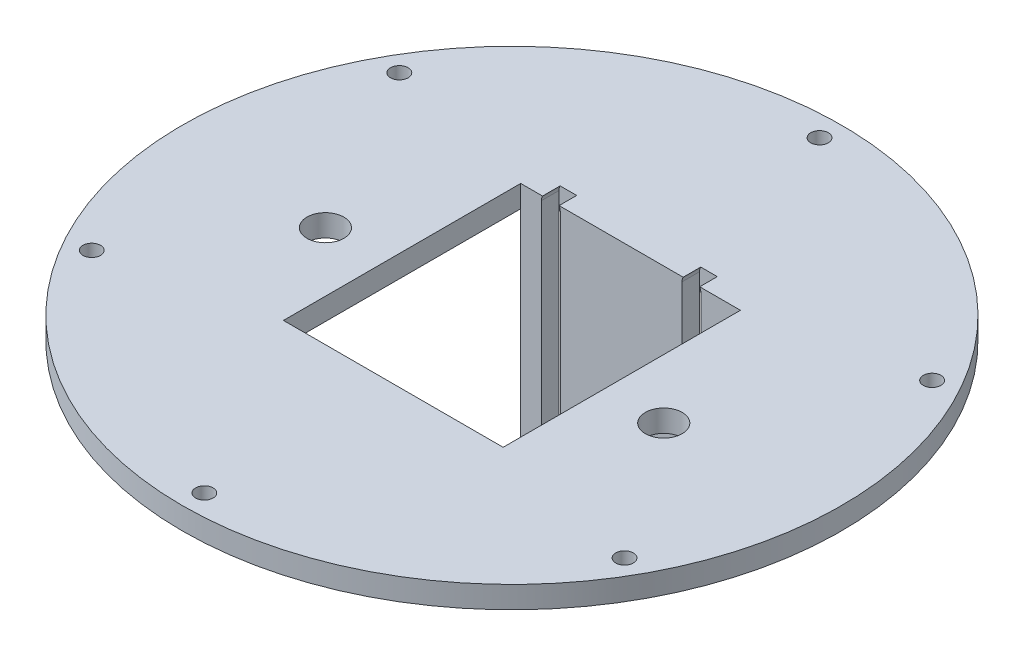
from build123d import *

# Parameters (mm, degrees)
SKETCH1_W           = 200
SKETCH1_H           = 100
BOSS_EXTRUDE1_DEPTH = 5
SKETCH2_W           = 50
SKETCH2_H           = 54
CUT_EXTRUDE1_DEPTH  = 6
SKETCH3_W           = 50
SKETCH3_H           = 4
BOSS_EXTRUDE2_DEPTH = 45
CUT_EXTRUDE3_DEPTH  = 4
SKETCH19_W          = 200
SKETCH19_H          = 5
BOSS_EXTRUDE3_DEPTH = 25
SKETCH20_W          = 200
SKETCH20_H          = 5
BOSS_EXTRUDE4_DEPTH = 25
SKETCH21_W          = 150
SKETCH21_H          = 5
BOSS_EXTRUDE5_DEPTH = 25
SKETCH22_OUTSIDE_W  = 282
SKETCH22_OUTSIDE_H  = 207
SKETCH22_OUTSIDE_R  = 75
CUT_EXTRUDE6_DEPTH  = 51
SKETCH26_R          = 2
CUT_EXTRUDE7_DEPTH  = 51
CUT_EXTRUDE8_REACH  = 52
SKETCH28_R          = 4.2
CUT_EXTRUDE10_DEPTH = 4


with BuildPart() as part:
    # Sketch1 → Boss-Extrude1 (new body)
    with BuildSketch(Plane(origin=(0, 0, 0), x_dir=(1, 0, 0), z_dir=(0, 1, 0))):
        Rectangle(SKETCH1_W, SKETCH1_H)
    extrude(amount=BOSS_EXTRUDE1_DEPTH)

    # Sketch2 → Cut-Extrude1 (cut, through all)
    with BuildSketch(Plane(origin=(0, 5, 0), x_dir=(1, 0, 0), z_dir=(0, 1, 0))):
        with Locations((30, 0)):
            Rectangle(SKETCH2_W, SKETCH2_H)
    extrude(amount=-CUT_EXTRUDE1_DEPTH, mode=Mode.SUBTRACT)

    # Sketch3 → Boss-Extrude2 (add)
    with BuildSketch(Plane.XZ):
        with Locations((30, -29)):
            Rectangle(SKETCH3_W, SKETCH3_H)
    extrude(amount=BOSS_EXTRUDE2_DEPTH)

    # Sketch4 → Cut-Extrude3 (cut)
    with BuildSketch(Plane.XY.offset(-27)):
        with BuildLine():
            ThreePointArc((14, 3.960327286), (11.85, 6.110327286), (9.7, 3.960327286))
            Line((9.7, 3.960327286), (9.7, -6.197738793))
            Line((9.7, -6.197738793), (14, -6.197264156))
            Line((14, -6.197264156), (14, 3.960327286))
        make_face()
        with BuildLine():
            Line((41.7, 3.960327286), (41.7, -31.94922721))
            ThreePointArc((41.7, -31.94922721), (43.85, -34.09922721), (46, -31.94922721))
            Line((46, -31.94922721), (46, 3.960327286))
            ThreePointArc((46, 3.960327286), (43.85, 6.110327286), (41.7, 3.960327286))
        make_face()
    extrude(amount=-CUT_EXTRUDE3_DEPTH, mode=Mode.SUBTRACT)

    # Sketch19 → Boss-Extrude3 (add)
    with BuildSketch(Plane(origin=(0, 0, -50), x_dir=(-1, 0, 0), z_dir=(0, 0, -1))):
        with Locations((0, 2.5)):
            Rectangle(SKETCH19_W, SKETCH19_H)
    extrude(amount=BOSS_EXTRUDE3_DEPTH)

    # Sketch20 → Boss-Extrude4 (add)
    with BuildSketch(Plane.XY.offset(50)):
        with Locations((0, 2.5)):
            Rectangle(SKETCH20_W, SKETCH20_H)
    extrude(amount=BOSS_EXTRUDE4_DEPTH)

    # Sketch21 → Boss-Extrude5 (add)
    with BuildSketch(Plane(origin=(100, 0, 0), x_dir=(0, 0, -1), z_dir=(1, 0, 0))):
        with Locations((0, 2.5)):
            Rectangle(SKETCH21_W, SKETCH21_H)
    extrude(amount=BOSS_EXTRUDE5_DEPTH)

    # Sketch22 outside → Cut-Extrude6 (cut, through all)
    with BuildSketch(Plane(origin=(0, 5, 0), x_dir=(1, 0, 0), z_dir=(0, 1, 0))):
        with Locations((12.5, 0)):
            Rectangle(SKETCH22_OUTSIDE_W, SKETCH22_OUTSIDE_H)
        with Locations((30, 0)):
            Circle(SKETCH22_OUTSIDE_R, mode=Mode.SUBTRACT)
    extrude(amount=-CUT_EXTRUDE6_DEPTH, mode=Mode.SUBTRACT)

    # Sketch26 → Cut-Extrude7 (cut, through all)
    with BuildSketch(Plane(origin=(0, 5, 0), x_dir=(1, 0, 0), z_dir=(0, 1, 0))):
        with Locations((30, -70)):
            Circle(SKETCH26_R)
        with Locations((-30.621778265, -35)):
            Circle(SKETCH26_R)
        with Locations((-30.621778265, 35)):
            Circle(SKETCH26_R)
        with Locations((30, 70)):
            Circle(SKETCH26_R)
        with Locations((90.621778265, 35)):
            Circle(SKETCH26_R)
        with Locations((90.621778265, -35)):
            Circle(SKETCH26_R)
    extrude(amount=-CUT_EXTRUDE7_DEPTH, mode=Mode.SUBTRACT)

    # Sketch28 → Cut-Extrude8 (cut, up to next)
    with BuildSketch(Plane(origin=(0, 5, 0), x_dir=(1, 0, 0), z_dir=(0, 1, 0)), mode=Mode.PRIVATE) as cut_extrude8_sk1:
        with Locations((-8.5, -3.95)):
            Circle(SKETCH28_R)
    cut_extrude8_tool1 = extrude(cut_extrude8_sk1.sketch, amount=-CUT_EXTRUDE8_REACH, mode=Mode.PRIVATE) & part.part
    add(cut_extrude8_tool1.solids().sort_by_distance((-8.5, 5, 3.95))[0], mode=Mode.SUBTRACT)
    # Sketch28 → Cut-Extrude8 (cut, up to next)
    with BuildSketch(Plane(origin=(0, 5, 0), x_dir=(1, 0, 0), z_dir=(0, 1, 0)), mode=Mode.PRIVATE) as cut_extrude8_sk2:
        with Locations((68.5, -3.95)):
            Circle(SKETCH28_R)
    cut_extrude8_tool2 = extrude(cut_extrude8_sk2.sketch, amount=-CUT_EXTRUDE8_REACH, mode=Mode.PRIVATE) & part.part
    add(cut_extrude8_tool2.solids().sort_by_distance((68.5, 5, 3.95))[0], mode=Mode.SUBTRACT)

    # Sketch30 → Cut-Extrude10 (cut)
    with BuildSketch(Plane.XY.offset(-27)):
        with BuildLine():
            Line((14, -6.197264156), (14, -40.571371384))
            ThreePointArc((14, -40.571371384), (11.85, -42.721371384), (9.7, -40.571371384))
            Line((9.7, -40.571371384), (9.7, -6.197738793))
            Line((9.7, -6.197738793), (14, -6.197264156))
        make_face()
        with BuildLine():
            Line((41.7, -31.94922721), (41.7, -36.94922721))
            ThreePointArc((41.7, -36.94922721), (43.85, -39.09922721), (46, -36.94922721))
            Line((46, -36.94922721), (46, -31.94922721))
            Line((46, -31.94922721), (41.7, -31.94922721))
        make_face()
    extrude(amount=-CUT_EXTRUDE10_DEPTH, mode=Mode.SUBTRACT)


solid = part.part
